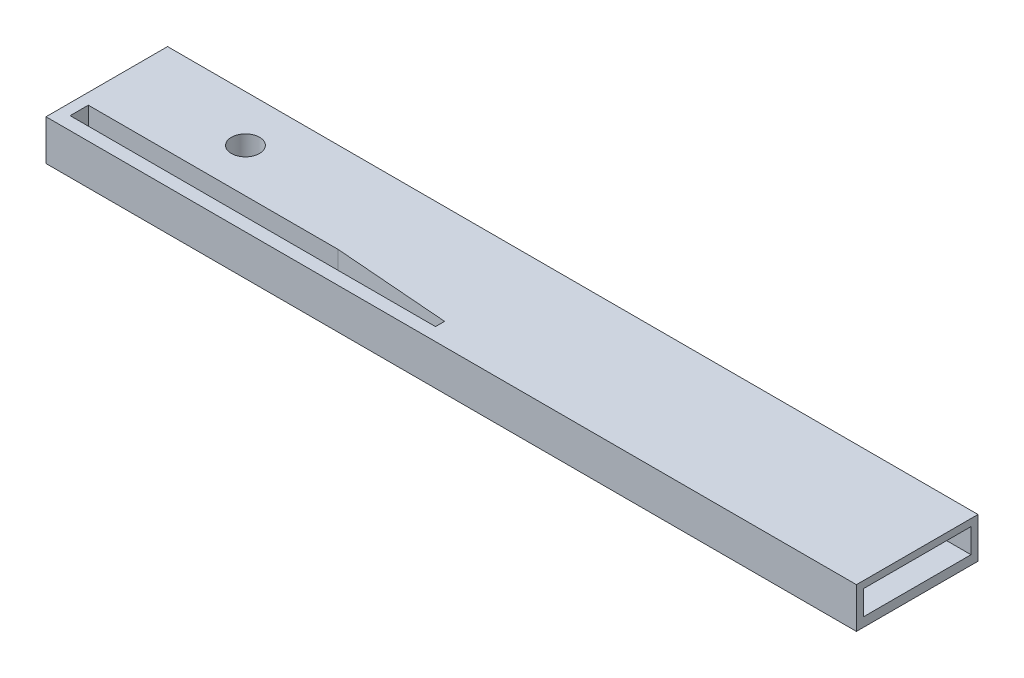
from build123d import *

# Parameters (mm, degrees)
SKETCH2_W           = 127
SKETCH2_H           = 19.05
BOSS_EXTRUDE1_DEPTH = 6.35
SKETCH3_W           = 16.857329018
SKETCH3_H           = 3.81675374
CUT_EXTRUDE1_DEPTH  = 6.35
CUT_EXTRUDE2_DEPTH  = 7.35
SKETCH5_R           = 2.208058356
CUT_EXTRUDE3_DEPTH  = 6.35


with BuildPart() as part:
    # Sketch2 → Boss-Extrude1 (new body)
    with BuildSketch(Plane(origin=(0, 0, 0), x_dir=(1, 0, 0), z_dir=(0, 1, 0))):
        Rectangle(SKETCH2_W, SKETCH2_H)
    extrude(amount=BOSS_EXTRUDE1_DEPTH)

    # Sketch3 → Cut-Extrude1 (cut)
    with BuildSketch(Plane(origin=(63.5, 0, 0), x_dir=(0, 0, -1), z_dir=(1, 0, 0))):
        with Locations((0, 3.343970869)):
            Rectangle(SKETCH3_W, SKETCH3_H)
    extrude(amount=-CUT_EXTRUDE1_DEPTH, mode=Mode.SUBTRACT)

    # Sketch4 → Cut-Extrude2 (cut, through all)
    with BuildSketch(Plane(origin=(0, 6.35, 0), x_dir=(1, 0, 0), z_dir=(0, 1, 0))):
        Polygon((-22.637713534, -4.636428392), (-4.505889832, -6.062078542), (-4.505889832, -7.487728691), (-61.757195928, -7.487728691), (-61.757195928, -4.636428392), align=None)
    extrude(amount=-CUT_EXTRUDE2_DEPTH, mode=Mode.SUBTRACT)

    # Sketch5 → Cut-Extrude3 (cut)
    with BuildSketch(Plane(origin=(0, 6.35, 0), x_dir=(1, 0, 0), z_dir=(0, 1, 0))):
        with Locations((-43.986162308, 2.214937446)):
            Circle(SKETCH5_R)
    extrude(amount=-CUT_EXTRUDE3_DEPTH, mode=Mode.SUBTRACT)


solid = part.part
